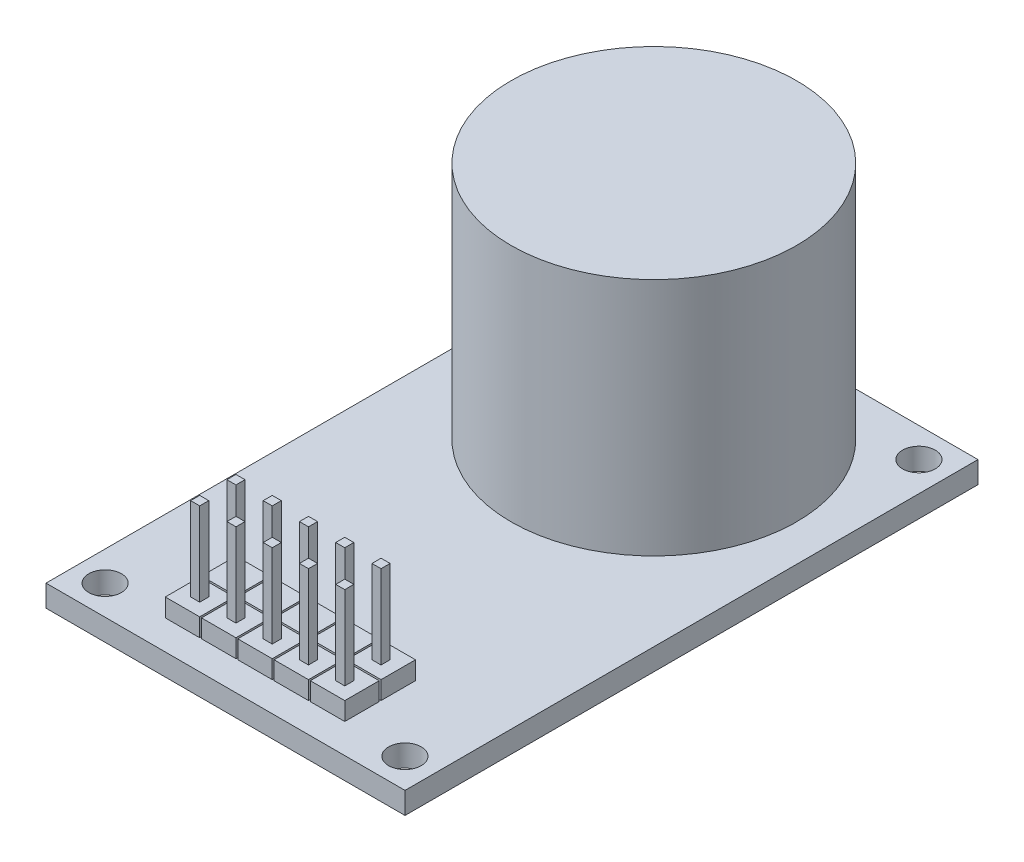
from build123d import *

# Parameters (mm, degrees)
SKETCH1_W           = 25.146
SKETCH1_H           = 40.132
SKETCH1_R           = 1.143
BOSS_EXTRUDE1_DEPTH = 1.524
SKETCH2_R           = 10
BOSS_EXTRUDE2_DEPTH = 16.764
SKETCH3_W           = 2.413
SKETCH3_H           = 2.413
BOSS_EXTRUDE3_DEPTH = 1.27
SKETCH4_W           = 0.635
SKETCH4_H           = 0.635
BOSS_EXTRUDE4_DEPTH = 5.842
SKETCH5_W           = 3.348930747
SKETCH5_H           = 5.720091757
BOSS_EXTRUDE5_DEPTH = 3.302


with BuildPart() as part:
    # Sketch1 → Boss-Extrude1 (new body)
    with BuildSketch(Plane(origin=(0, 0, 0), x_dir=(1, 0, 0), z_dir=(0, 1, 0))):
        with Locations((12.573, 20.066)):
            Rectangle(SKETCH1_W, SKETCH1_H)
        with Locations((2.073, 38.066)):
            Circle(SKETCH1_R, mode=Mode.SUBTRACT)
        with Locations((23.073, 38.066)):
            Circle(SKETCH1_R, mode=Mode.SUBTRACT)
        with Locations((23.073, 2.066)):
            Circle(SKETCH1_R, mode=Mode.SUBTRACT)
        with Locations((2.073, 2.066)):
            Circle(SKETCH1_R, mode=Mode.SUBTRACT)
    extrude(amount=BOSS_EXTRUDE1_DEPTH)

    # Sketch2 → Boss-Extrude2 (add)
    with BuildSketch(Plane(origin=(0, 1.524, 0), x_dir=(1, 0, 0), z_dir=(0, 1, 0))):
        with Locations((12.573, 30)):
            Circle(SKETCH2_R)
    extrude(amount=BOSS_EXTRUDE2_DEPTH)

    # Sketch3 → Boss-Extrude3 (add)
    with BuildSketch(Plane(origin=(0, 1.524, 0), x_dir=(1, 0, 0), z_dir=(0, 1, 0))):
        with Locations((7.493, 3.2725)):
            Rectangle(SKETCH3_W, SKETCH3_H)
        with Locations((10.033, 3.2725)):
            Rectangle(SKETCH3_W, SKETCH3_H)
        with Locations((12.573, 3.2725)):
            Rectangle(SKETCH3_W, SKETCH3_H)
        with Locations((15.113, 3.2725)):
            Rectangle(SKETCH3_W, SKETCH3_H)
        with Locations((17.653, 3.2725)):
            Rectangle(SKETCH3_W, SKETCH3_H)
        with Locations((7.493, 5.8125)):
            Rectangle(SKETCH3_W, SKETCH3_H)
        with Locations((10.033, 5.8125)):
            Rectangle(SKETCH3_W, SKETCH3_H)
        with Locations((12.573, 5.8125)):
            Rectangle(SKETCH3_W, SKETCH3_H)
        with Locations((15.113, 5.8125)):
            Rectangle(SKETCH3_W, SKETCH3_H)
        with Locations((17.653, 5.8125)):
            Rectangle(SKETCH3_W, SKETCH3_H)
    extrude(amount=BOSS_EXTRUDE3_DEPTH)

    # Sketch4 → Boss-Extrude4 (add)
    with BuildSketch(Plane(origin=(0, 2.794, 0), x_dir=(1, 0, 0), z_dir=(0, 1, 0))):
        with Locations((10.033, 3.2725)):
            Rectangle(SKETCH4_W, SKETCH4_H)
        with Locations((7.493, 3.2725)):
            Rectangle(SKETCH4_W, SKETCH4_H)
        with Locations((12.573, 3.2725)):
            Rectangle(SKETCH4_W, SKETCH4_H)
        with Locations((15.113, 3.2725)):
            Rectangle(SKETCH4_W, SKETCH4_H)
        with Locations((17.653, 3.2725)):
            Rectangle(SKETCH4_W, SKETCH4_H)
        with Locations((10.033, 5.8125)):
            Rectangle(SKETCH4_W, SKETCH4_H)
        with Locations((12.573, 5.8125)):
            Rectangle(SKETCH4_W, SKETCH4_H)
        with Locations((15.113, 5.8125)):
            Rectangle(SKETCH4_W, SKETCH4_H)
        with Locations((17.653, 5.8125)):
            Rectangle(SKETCH4_W, SKETCH4_H)
        with Locations((7.493, 5.8125)):
            Rectangle(SKETCH4_W, SKETCH4_H)
    extrude(amount=BOSS_EXTRUDE4_DEPTH)

    # Sketch5 → Boss-Extrude5 (add)
    with BuildSketch(Plane.XZ):
        with Locations((3.215733766, -29.18090344)):
            Rectangle(SKETCH5_W, SKETCH5_H)
    extrude(amount=BOSS_EXTRUDE5_DEPTH)


solid = part.part
